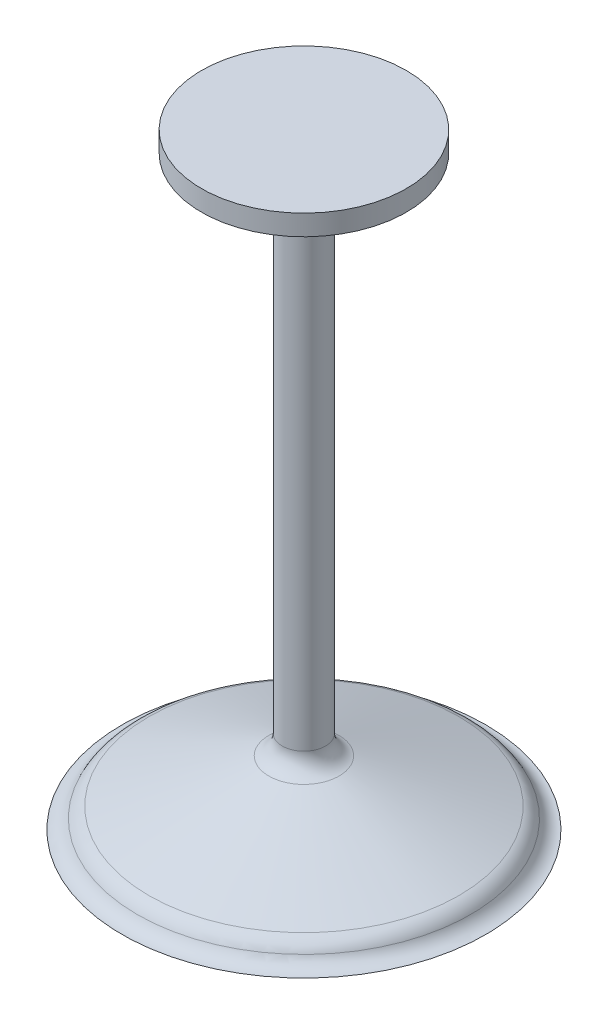
from build123d import *


with BuildPart() as part:
    # Sketch1 → Revolve1 (revolve)
    with BuildSketch(Plane.XY):
        with BuildLine():
            Line((23.51811505, 0), (26.625, 0))
            ThreePointArc((26.625, 0), (25.304396139, 0.386385346), (24.400332669, 1.423669028))
            ThreePointArc((24.400332669, 1.423669028), (23.707536564, 2.374622845), (22.702310652, 2.986015087))
            Line((22.702310652, 2.986015087), (5.14893957, 9.374919672))
            ThreePointArc((5.14893957, 9.374919672), (3.717543867, 10.473268225), (3.175, 12.193997534))
            Line((3.175, 12.193997534), (3.175, 85.8))
            Line((3.175, 85.8), (15, 85.8))
            Line((15, 85.8), (15, 88.8))
            Line((15, 88.8), (0, 88.8))
            Line((0, 88.8), (0, 5))
            ThreePointArc((0, 5), (7.986491275, 4.057468663), (15.648056713, 1.613532646))
            ThreePointArc((15.648056713, 1.613532646), (19.501234861, 0.407535287), (23.51811505, 0))
        make_face()
    revolve(axis=Axis((0, -88.8, 0), (0, 1, 0)))


solid = part.part
